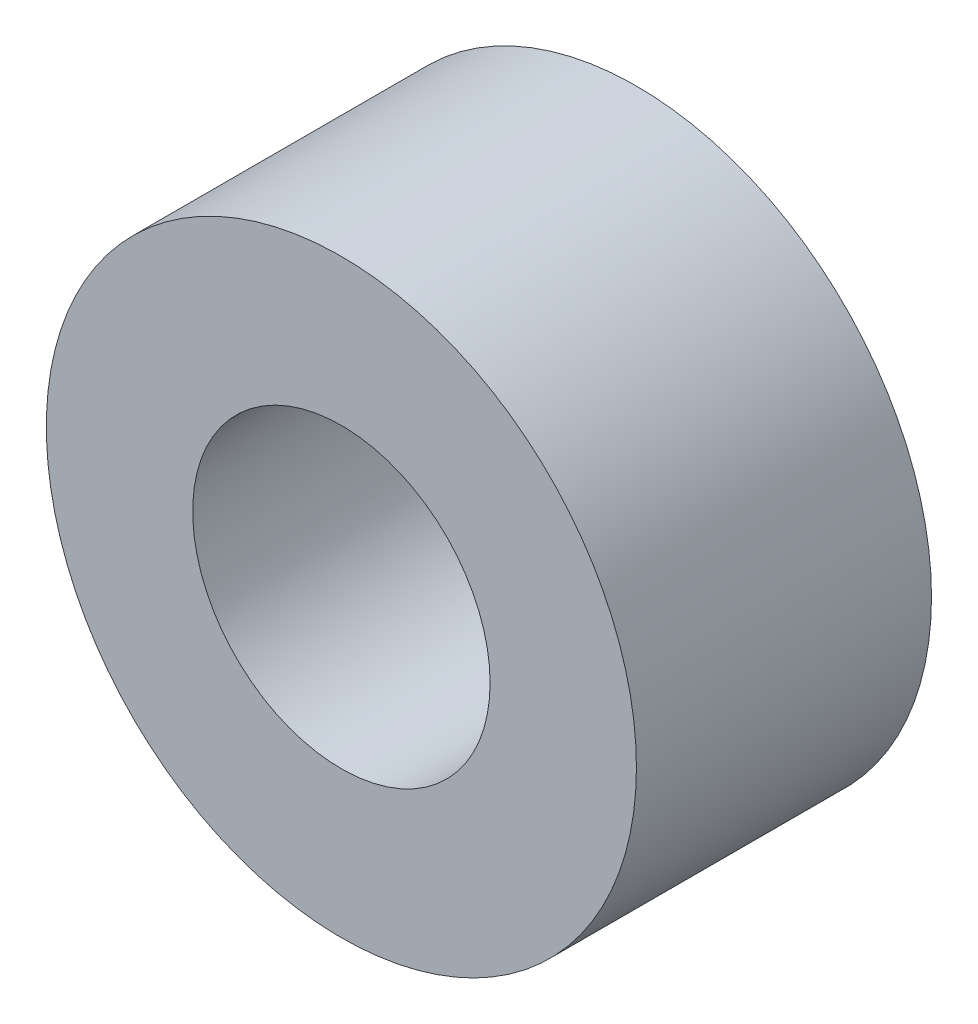
from build123d import *

# Parameters (mm, degrees)
SKETCH1_R      = 6.35
SKETCH1_R_2    = 3.2004
EXTRUDE1_DEPTH = 3.175


with BuildPart() as part:
    # Sketch1 → Extrude1 (new body, symmetric)
    with BuildSketch(Plane.XY):
        Circle(SKETCH1_R)
        Circle(SKETCH1_R_2, mode=Mode.SUBTRACT)
    extrude(amount=EXTRUDE1_DEPTH, both=True)


solid = part.part
